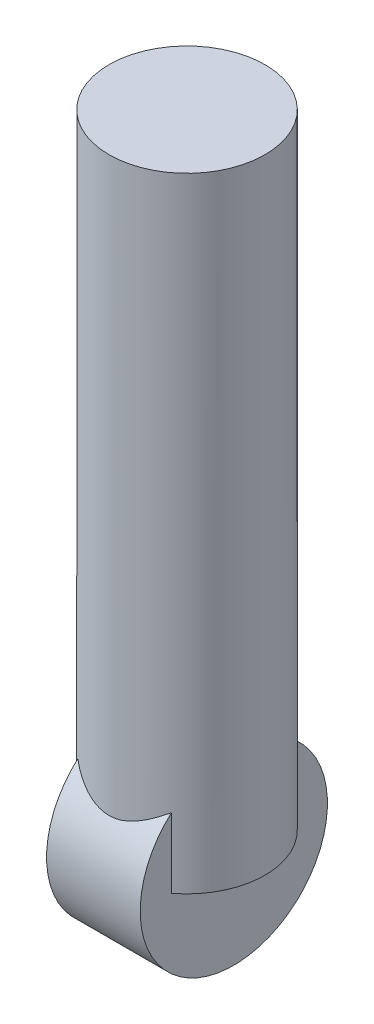
from build123d import *

# Parameters (mm, degrees)
SKETCH1_R           = 25
BOSS_EXTRUDE1_DEPTH = 200
SKETCH9_R           = 30
BOSS_EXTRUDE4_DEPTH = 15


with BuildPart() as part:
    # Sketch1 → Boss-Extrude1 (new body)
    with BuildSketch(Plane(origin=(0, 0, 0), x_dir=(1, 0, 0), z_dir=(0, 1, 0))):
        Circle(SKETCH1_R)
    extrude(amount=BOSS_EXTRUDE1_DEPTH)

    # Sketch9 → Boss-Extrude4 (add, symmetric)
    with BuildSketch(Plane(origin=(0, 0, 0), x_dir=(0, 0, -1), z_dir=(1, 0, 0))):
        Circle(SKETCH9_R)
    extrude(amount=BOSS_EXTRUDE4_DEPTH, both=True)


solid = part.part
